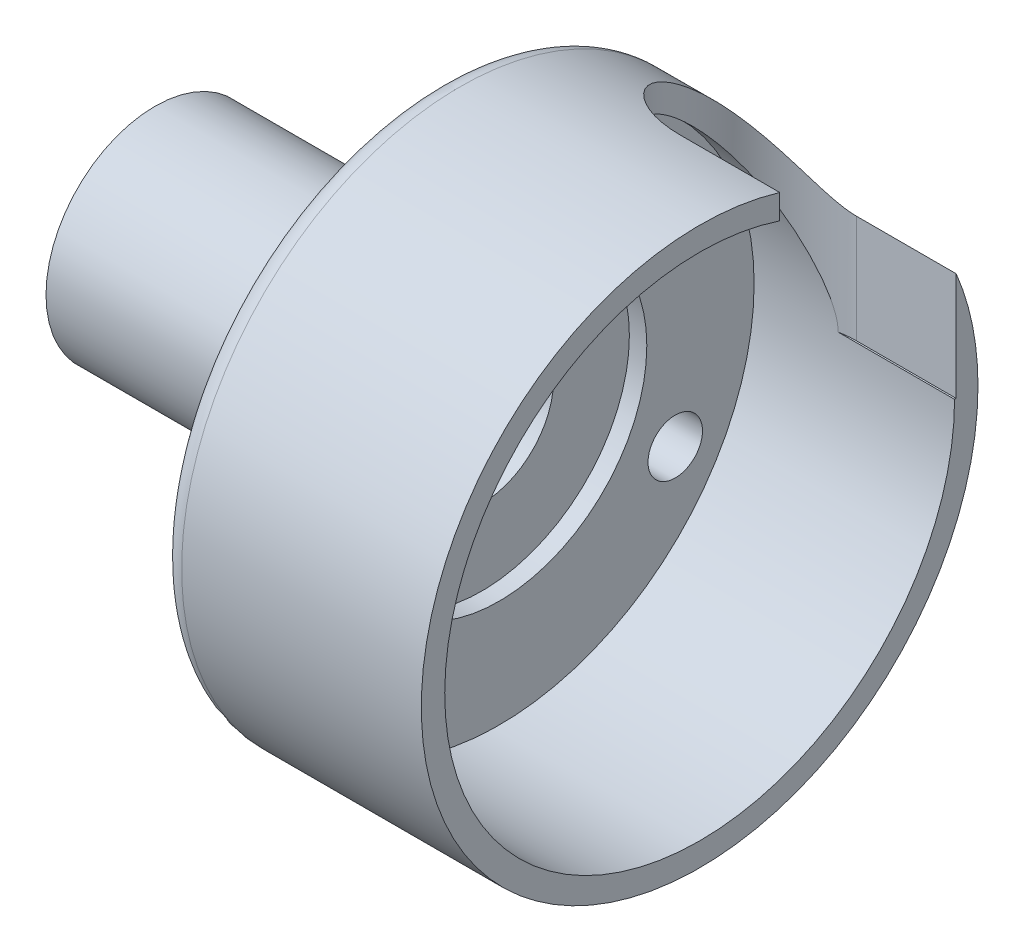
from build123d import *

# Parameters (mm, degrees)
SKETCH3_R                = 5
SKETCH3_R_2              = 3.3
BOSS_EXTRUDE3_DEPTH      = 10
BOSS_EXTRUDE3_DEPTH_BACK = 5
SKETCH10_R               = 12.775
SKETCH10_R_2             = 3.65
BOSS_EXTRUDE5_DEPTH      = 2
SKETCH11_R               = 11.275
SKETCH11_R_2             = 6.775
BOSS_EXTRUDE6_DEPTH      = 0.8
SKETCH12_R               = 1.25
CUT_EXTRUDE2_DEPTH       = 2.75
FILLET3_R                = 1
SKETCH13_R               = 12.775
SKETCH13_R_2             = 11.275
BOSS_EXTRUDE7_DEPTH      = 10
SKETCH14_R               = 11.7
CUT_EXTRUDE3_DEPTH       = 9.2
CUT_EXTRUDE5_DEPTH       = 16
SKETCH16_R               = 4
CUT_EXTRUDE6_DEPTH       = 14


with BuildPart() as part:
    # Sketch3 → Boss-Extrude3 (new body, two sides)
    with BuildSketch(Plane(origin=(0, 0, 0), x_dir=(0, 0, -1), z_dir=(1, 0, 0))) as boss_extrude3_sk:
        Circle(SKETCH3_R)
        Circle(SKETCH3_R_2, mode=Mode.SUBTRACT)
    extrude(amount=BOSS_EXTRUDE3_DEPTH)
    extrude(boss_extrude3_sk.sketch, amount=-BOSS_EXTRUDE3_DEPTH_BACK)

    # Sketch10 → Boss-Extrude5 (add)
    with BuildSketch(Plane(origin=(10, 0, 0), x_dir=(0, 0, -1), z_dir=(1, 0, 0))):
        Circle(SKETCH10_R)
        Circle(SKETCH10_R_2, mode=Mode.SUBTRACT)
    extrude(amount=-BOSS_EXTRUDE5_DEPTH)

    # Sketch11 → Boss-Extrude6 (add)
    with BuildSketch(Plane(origin=(10, 0, 0), x_dir=(0, 0, -1), z_dir=(1, 0, 0))):
        Circle(SKETCH11_R)
        Circle(SKETCH11_R_2, mode=Mode.SUBTRACT)
    extrude(amount=BOSS_EXTRUDE6_DEPTH)

    # Sketch12 → Cut-Extrude2 (cut)
    with BuildSketch(Plane(origin=(10.8, 0, 0), x_dir=(0, 0, -1), z_dir=(1, 0, 0))):
        with BuildLine():
            ThreePointArc((9.330017017, -4.665), (8.705017017, -3.582468245), (7.455017017, -3.582468245))
            Line((7.455017017, -3.582468245), (8.080017017, -4.665))
            Line((8.080017017, -4.665), (6.830017017, -4.665))
            ThreePointArc((6.830017017, -4.665), (8.080017017, -5.915), (9.330017017, -4.665))
        make_face()
        with BuildLine():
            Line((8.080017017, -4.665), (7.455017017, -3.582468245))
            ThreePointArc((7.455017017, -3.582468245), (6.997485263, -4.04), (6.830017017, -4.665))
            Line((6.830017017, -4.665), (8.080017017, -4.665))
        make_face()
        with BuildLine():
            Line((0.625, 8.247468245), (0, 9.33))
            Line((0, 9.33), (-0.625, 8.247468245))
            ThreePointArc((-0.625, 8.247468245), (0, 8.08), (0.625, 8.247468245))
        make_face()
        with BuildLine():
            Line((-0.625, 8.247468245), (0, 9.33))
            Line((0, 9.33), (0.625, 8.247468245))
            ThreePointArc((0.625, 8.247468245), (1.082531755, 8.705), (1.25, 9.33))
            ThreePointArc((1.25, 9.33), (-0.625, 10.412531755), (-0.625, 8.247468245))
        make_face()
        with Locations((-8.080017017, -4.665)):
            Circle(SKETCH12_R)
    extrude(amount=-CUT_EXTRUDE2_DEPTH, mode=Mode.SUBTRACT)

    # Fillet3
    fillet3_edges = [part.edges().sort_by_distance(p)[0] for p in [
        (8, 0, 12.775),
    ]]
    fillet(fillet3_edges, radius=FILLET3_R)

    # Sketch13 → Boss-Extrude7 (add)
    with BuildSketch(Plane(origin=(10, 0, 0), x_dir=(0, 0, -1), z_dir=(1, 0, 0))):
        Circle(SKETCH13_R)
        Circle(SKETCH13_R_2, mode=Mode.SUBTRACT)
    extrude(amount=BOSS_EXTRUDE7_DEPTH)

    # Sketch14 → Cut-Extrude3 (cut)
    with BuildSketch(Plane(origin=(20, 0, 0), x_dir=(0, 0, -1), z_dir=(1, 0, 0))):
        Circle(SKETCH14_R)
    extrude(amount=-CUT_EXTRUDE3_DEPTH, mode=Mode.SUBTRACT)

    # Sketch15 → Cut-Extrude5 (cut)
    with BuildSketch(Plane(origin=(0, 0, 0), x_dir=(1, 0, 0), z_dir=(0, 1, 0))):
        with BuildLine():
            Line((15.430071931, 3.675), (20, 3.675))
            Line((20, 3.675), (20, 11.775))
            Line((20, 11.775), (15.430071931, 11.775))
            ThreePointArc((15.430071931, 11.775), (11.380071931, 7.725), (15.430071931, 3.675))
        make_face()
    extrude(amount=CUT_EXTRUDE5_DEPTH, mode=Mode.SUBTRACT)

    # Sketch16 → Cut-Extrude6 (cut)
    with BuildSketch(Plane.ZY.offset(5)):
        Circle(SKETCH16_R)
    extrude(amount=-CUT_EXTRUDE6_DEPTH, mode=Mode.SUBTRACT)


solid = part.part
